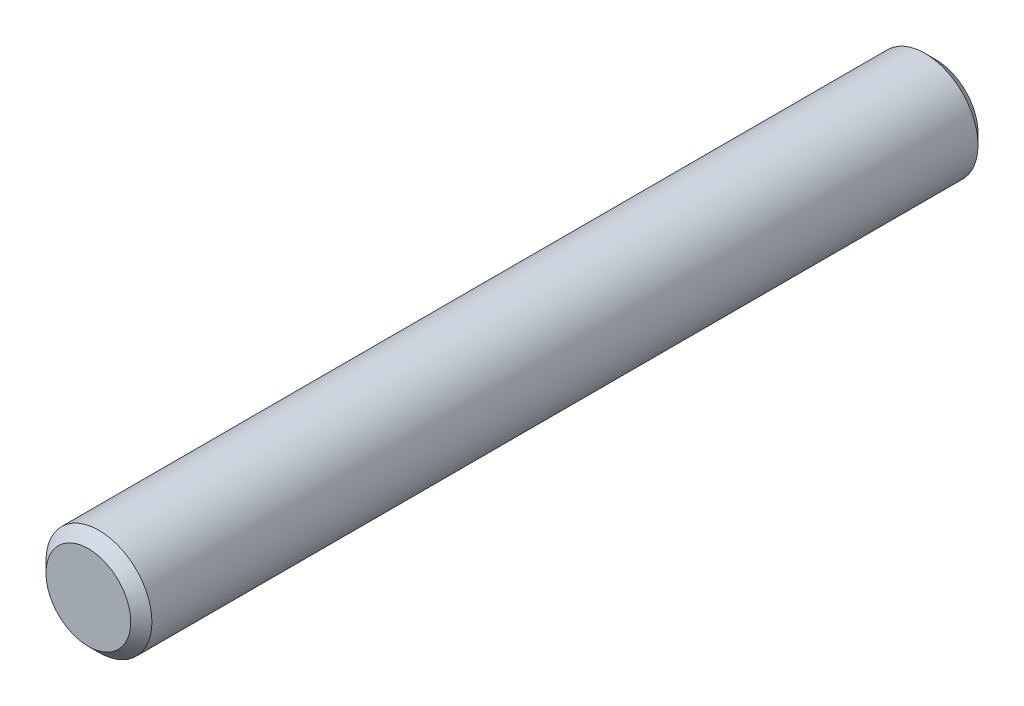
from build123d import *


with BuildPart() as part:
    # Sketch1 → Revolve1 (revolve)
    with BuildSketch(Plane(origin=(0, 0, 0), x_dir=(1, 0, 0), z_dir=(0, 1, 0))):
        Polygon((1.2, 12), (0, 12), (0, -12), (1.2, -12), (1.5, -11.7), (1.5, 11.7), align=None)
    revolve(axis=Axis((0, 0, -12), (0, 0, 1)))


solid = part.part
